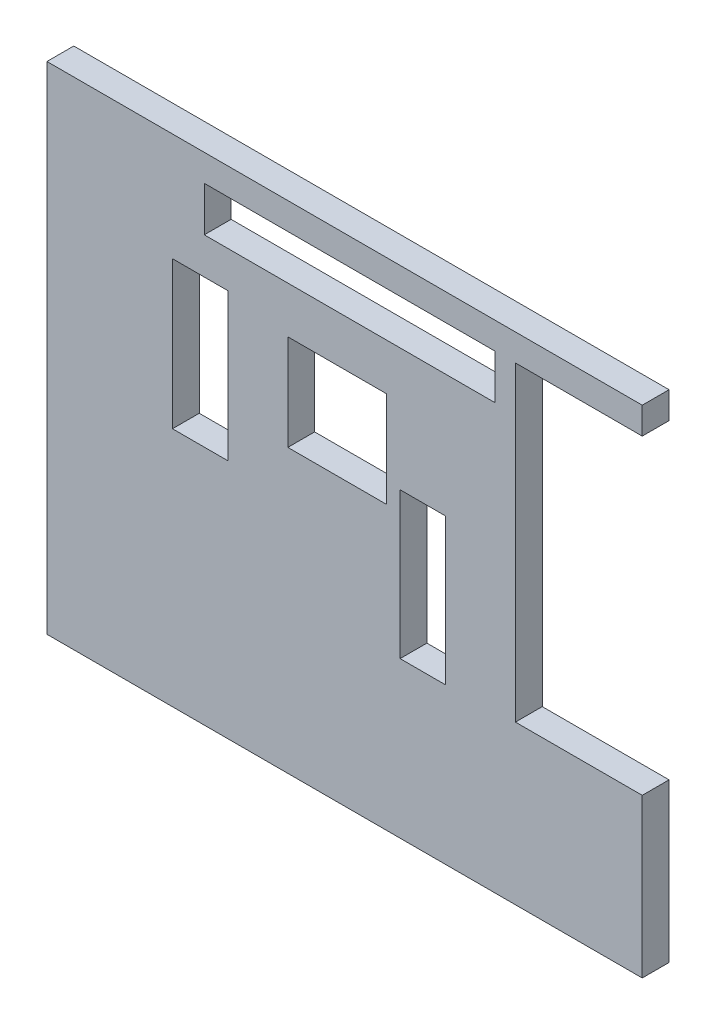
from build123d import *

# Parameters (mm, degrees)
CROQUIS1_W              = 54.203553954
CROQUIS1_H              = 8.324117214
CROQUIS1_W_2            = 10.370081464
CROQUIS1_H_2            = 27.461512026
CROQUIS1_W_3            = 8.449696009
CROQUIS1_H_3            = 27.269473481
CROQUIS1_W_4            = 18.435700381
CROQUIS1_H_4            = 17.859584744
SALIENTE_EXTRUIR1_DEPTH = 5
CROQUIS3_W              = 111
CROQUIS3_H              = 5
SALIENTE_EXTRUIR2_DEPTH = 6


with BuildPart() as part:
    # Croquis1 → Saliente-Extruir1 (new body)
    with BuildSketch(Plane.XY):
        Polygon((0.553582562, 91.831917191), (0.553582562, 5.331917191), (111.553582562, 5.331917191), (111.553582562, 28.831917191), (87.909456329, 28.831917191), (87.909456329, 86.831917191), (111.553582562, 86.831917191), (111.553582562, 91.831917191), align=None)
        with Locations((56.991342937, 82.669858584)):
            Rectangle(CROQUIS1_W, CROQUIS1_H, mode=Mode.SUBTRACT)
        with Locations((29.145661363, 57.958361113)):
            Rectangle(CROQUIS1_W_2, CROQUIS1_H_2, mode=Mode.SUBTRACT)
        with Locations((70.625987221, 41.966653932)):
            Rectangle(CROQUIS1_W_3, CROQUIS1_H_3, mode=Mode.SUBTRACT)
        with Locations((54.686787933, 60.902124819)):
            Rectangle(CROQUIS1_W_4, CROQUIS1_H_4, mode=Mode.SUBTRACT)
    extrude(amount=SALIENTE_EXTRUIR1_DEPTH)

    # Croquis3 → Saliente-Extruir2 (add)
    with BuildSketch(Plane.XZ.offset(-5.331917191)):
        with Locations((56.053582562, 2.5)):
            Rectangle(CROQUIS3_W, CROQUIS3_H)
    extrude(amount=SALIENTE_EXTRUIR2_DEPTH)


solid = part.part
